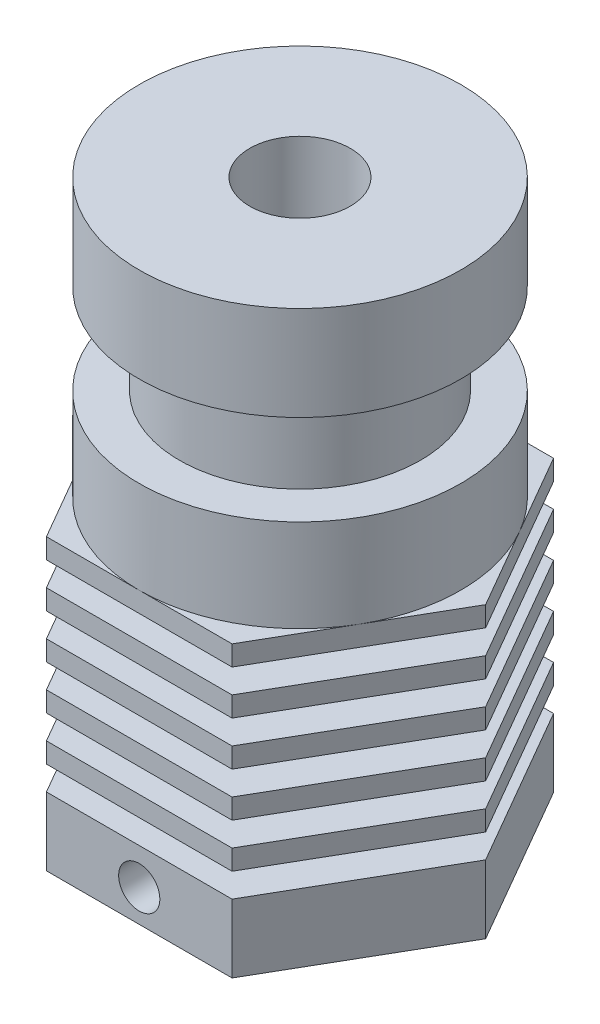
from build123d import *

# Parameters (mm, degrees)
SKETCH2_OUTSIDE_W            = 40.48
SKETCH2_OUTSIDE_H            = 40.48
CUT_EXTRUDE1_DEPTH           = 15.4
M6X1_0_TAPPED_HOLE1_D        = 5
M6X1_0_TAPPED_HOLE1_DEPTH    = 5
M6X1_0_TAPPED_HOLE1_TIP      = 1.502151548
M2_5X0_45_TAPPED_HOLE1_D     = 2.05
M2_5X0_45_TAPPED_HOLE1_DEPTH = 9
M2_5X0_45_TAPPED_HOLE1_TIP   = 0.615882135


with BuildPart() as part:
    # Sketch1 → Revolve1 (revolve)
    with BuildSketch(Plane.XY, mode=Mode.PRIVATE) as revolve1_sk:
        Polygon((3, 0), (3, 3.2), (2.05, 3.2), (2.05, 28.2), (8, 28.2), (8, 23.5), (6, 23.5), (6, 19), (8, 19), (8, 14.4), (14.307769621, 14.4), (14.307769621, 13.4), (4.75, 13.4), (4.75, 12.2), (14.307769621, 12.2), (14.307769621, 11.2), (4.75, 11.2), (4.75, 10), (14.307769621, 10), (14.307769621, 9), (4.75, 9), (4.75, 7.8), (14.307769621, 7.8), (14.307769621, 6.8), (4.75, 6.8), (4.75, 5.6), (14.307769621, 5.6), (14.307769621, 4.6), (4.75, 4.6), (4.75, 3.4), (14.307769621, 3.4), (14.307769621, 0), align=None)
    revolve(revolve1_sk.sketch.rotate(Axis((0, 0, 0), (0, 1, 0)), 90), axis=Axis((0, 0, 0), (0, 1, 0)))  # turned: the seam where the file's is

    # Sketch2 outside → Cut-Extrude1 (cut, through all)
    with BuildSketch(Plane(origin=(0, 14.4, 0), x_dir=(1, 0, 0), z_dir=(0, 1, 0))):
        Rectangle(SKETCH2_OUTSIDE_W, SKETCH2_OUTSIDE_H)
        Polygon((-4.618802154, 8), (-9.237604307, 0), (-4.618802154, -8), (4.618802154, -8), (9.237604307, 0), (4.618802154, 8), align=None, mode=Mode.SUBTRACT)
    extrude(amount=-CUT_EXTRUDE1_DEPTH, mode=Mode.SUBTRACT)

    # M6x1.0 Tapped Hole1
    with Locations(Plane(origin=(0, 28.2, 0), x_dir=(-1, 0, 0), z_dir=(0, 1, 0))):
        with Locations((0, 0)):
            Hole(M6X1_0_TAPPED_HOLE1_D / 2, depth=M6X1_0_TAPPED_HOLE1_DEPTH)
            with Locations((0, 0, -(M6X1_0_TAPPED_HOLE1_DEPTH + M6X1_0_TAPPED_HOLE1_TIP / 2))):  # 118° drill point
                Cone(0, M6X1_0_TAPPED_HOLE1_D / 2, M6X1_0_TAPPED_HOLE1_TIP, mode=Mode.SUBTRACT)

    # M2.5x0.45 Tapped Hole1
    with Locations(Plane.XY.offset(8)):
        with Locations((0, 1.6)):
            Hole(M2_5X0_45_TAPPED_HOLE1_D / 2, depth=M2_5X0_45_TAPPED_HOLE1_DEPTH)
            with Locations((0, 0, -(M2_5X0_45_TAPPED_HOLE1_DEPTH + M2_5X0_45_TAPPED_HOLE1_TIP / 2))):  # 118° drill point
                Cone(0, M2_5X0_45_TAPPED_HOLE1_D / 2, M2_5X0_45_TAPPED_HOLE1_TIP, mode=Mode.SUBTRACT)


solid = part.part
